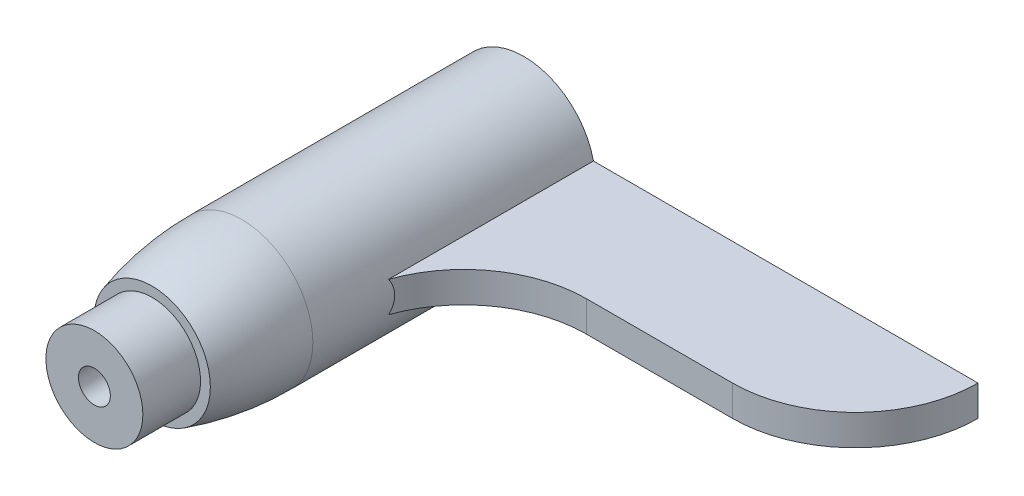
from build123d import *

# Parameters (mm, degrees)
SKETCH1_R           = 5.8
BOSS_EXTRUDE1_DEPTH = 23
BOSS_EXTRUDE2_DEPTH = 1.25
SKETCH4_R           = 1.3
CUT_EXTRUDE1_DEPTH  = 36.0000001


with BuildPart() as part:
    # Sketch1 → Boss-Extrude1 (new body)
    with BuildSketch(Plane.XY):
        Circle(SKETCH1_R)
    extrude(amount=BOSS_EXTRUDE1_DEPTH)

    # Sketch2 → Boss-Extrude2 (add, symmetric)
    with BuildSketch(Plane(origin=(0, 0, 0), x_dir=(1, 0, 0), z_dir=(0, 1, 0))):
        with BuildLine():
            Line((0, 0), (37, 0))
            ThreePointArc((37, 0), (34.071067812, -7.071067812), (27, -10))
            Line((27, -10), (15.101535324, -10))
            ThreePointArc((15.101535324, -10), (8.030467512, -12.928932188), (5.101535324, -20))
            Line((5.101535324, -20), (0, -20))
            Line((0, -20), (0, 0))
        make_face()
    extrude(amount=BOSS_EXTRUDE2_DEPTH, both=True)

    # Sketch3 → Revolve1 (revolve)
    with BuildSketch(Plane(origin=(0, 0, 0), x_dir=(1, 0, 0), z_dir=(0, 1, 0))):
        with BuildLine():
            Line((0, -23), (-5.8, -23))
            ThreePointArc((-5.8, -23), (-5.536156171, -26.687563559), (-4.75, -30.3))
            Line((-4.75, -30.3), (-3.95, -30.3))
            Line((-3.95, -30.3), (-3.95, -35))
            Line((-3.95, -35), (0, -35))
            Line((0, -35), (0, -23))
        make_face()
    revolve(axis=Axis((0, 0, 1000), (0, 0, -1)))

    # Sketch4 → Cut-Extrude1 (cut, through all)
    with BuildSketch(Plane.XY.offset(35)):
        Circle(SKETCH4_R)
    extrude(amount=-CUT_EXTRUDE1_DEPTH, mode=Mode.SUBTRACT)


solid = part.part
